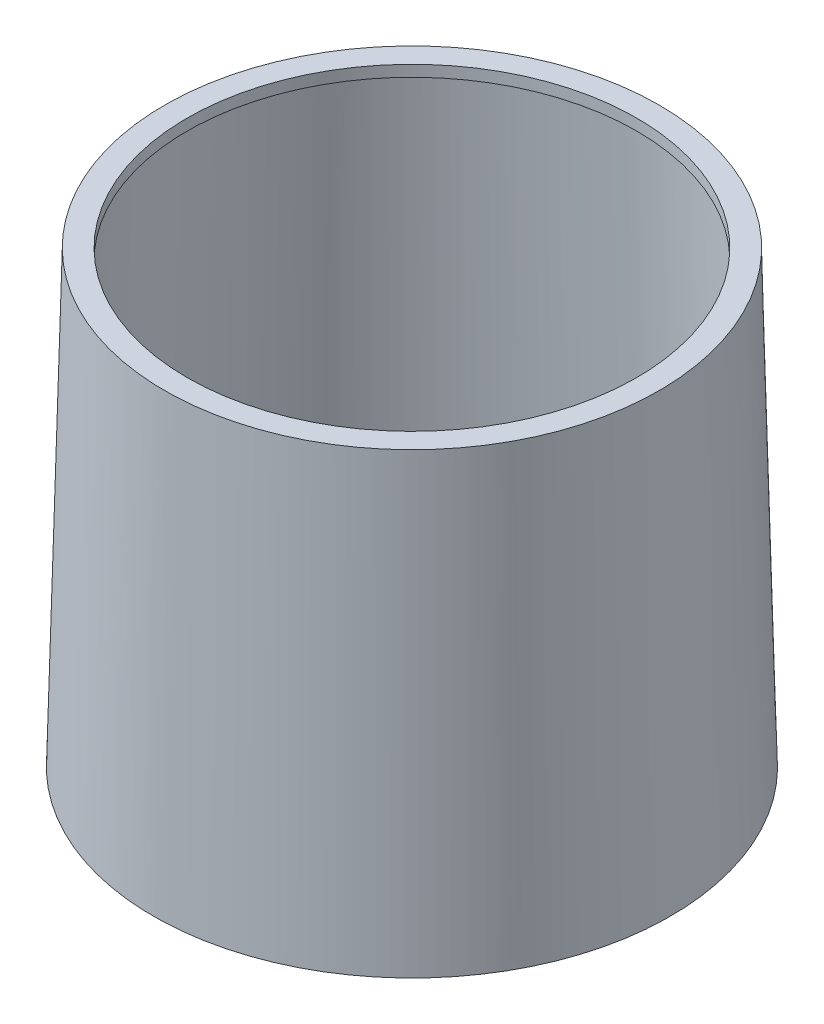
from build123d import *

# Parameters (mm, degrees)
SKETCH6_R          = 10
CUT_EXTRUDE1_DEPTH = 20
SKETCH8_R          = 11
SKETCH8_R_2        = 10.5
CUT_EXTRUDE3_DEPTH = 0.5


with BuildPart() as part:
    # Sketch3 → Revolve1 (revolve)
    with BuildSketch(Plane.XY):
        Polygon((0, 0), (11.5, 0), (11, 20), (0, 20), align=None)
    revolve(axis=Axis((0, 0, 0), (0, 1, 0)))

    # Sketch6 → Cut-Extrude1 (cut)
    with BuildSketch(Plane(origin=(0, 20, 0), x_dir=(1, 0, 0), z_dir=(0, 1, 0))):
        Circle(SKETCH6_R)
    extrude(amount=-CUT_EXTRUDE1_DEPTH, mode=Mode.SUBTRACT)

    # Sketch7 → Cut-Revolve1 (revolve, cut)
    with BuildSketch(Plane.XY):
        Polygon((10, 19.5), (10, 0.5), (11.250026684, 0.5), (10.607608939, 19.5), align=None)
    revolve(axis=Axis((0, 0, 0), (0, 1, 0)), mode=Mode.SUBTRACT)

    # Sketch8 → Cut-Extrude3 (cut)
    with BuildSketch(Plane(origin=(0, 0, 0), x_dir=(-1, 0, 0), z_dir=(0, -1, 0))):
        Circle(SKETCH8_R)
        Circle(SKETCH8_R_2, mode=Mode.SUBTRACT)
    extrude(amount=-CUT_EXTRUDE3_DEPTH, mode=Mode.SUBTRACT)


solid = part.part
